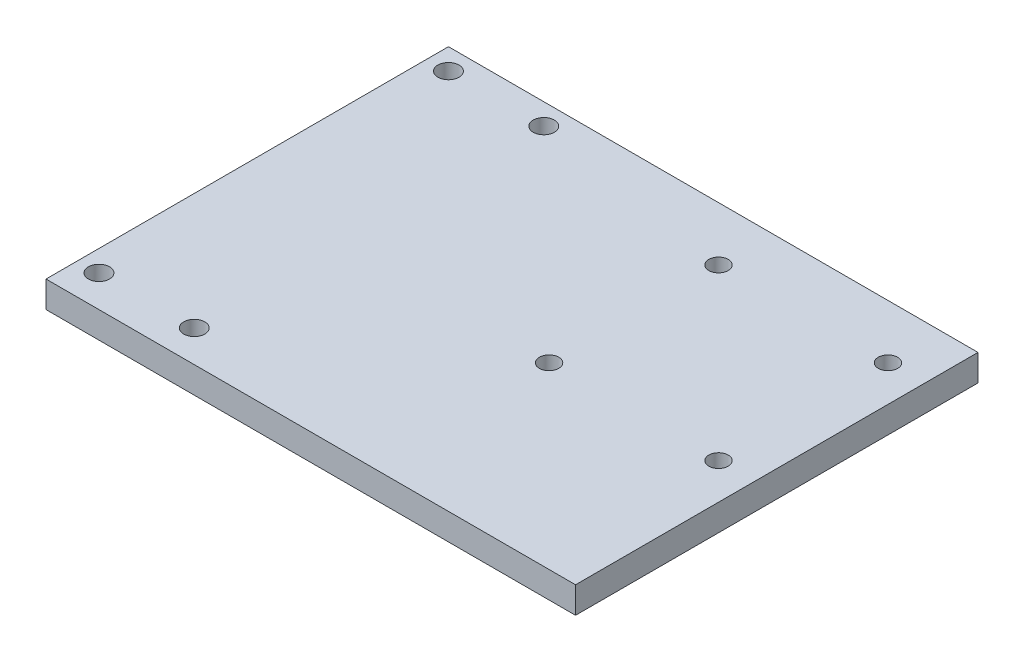
from build123d import *

# Parameters (mm, degrees)
SKETCH1_W           = 100
SKETCH1_H           = 76
BOSS_EXTRUDE1_DEPTH = 5
CUT_EXTRUDE6_REACH  = 7
SKETCH2_R           = 2
SKETCH2_R_2         = 1.832419899


with BuildPart() as part:
    # Sketch1 → Boss-Extrude1 (new body)
    with BuildSketch(Plane(origin=(0, 0, 0), x_dir=(1, 0, 0), z_dir=(0, 1, 0))):
        Rectangle(SKETCH1_W, SKETCH1_H)
    extrude(amount=BOSS_EXTRUDE1_DEPTH)

    # Sketch2 → Cut-Extrude6 (cut, up to next)
    with BuildSketch(Plane(origin=(0, 5, 0), x_dir=(1, 0, 0), z_dir=(0, 1, 0)), mode=Mode.PRIVATE) as cut_extrude6_sk1:
        with Locations((-46, 34)):
            Circle(SKETCH2_R)
    cut_extrude6_tool1 = extrude(cut_extrude6_sk1.sketch, amount=-CUT_EXTRUDE6_REACH, mode=Mode.PRIVATE) & part.part
    add(cut_extrude6_tool1.solids().sort_by_distance((-46, 5, -34))[0], mode=Mode.SUBTRACT)
    # Sketch2 → Cut-Extrude6 (cut, up to next)
    with BuildSketch(Plane(origin=(0, 5, 0), x_dir=(1, 0, 0), z_dir=(0, 1, 0)), mode=Mode.PRIVATE) as cut_extrude6_sk2:
        with Locations((-28, 34)):
            Circle(SKETCH2_R)
    cut_extrude6_tool2 = extrude(cut_extrude6_sk2.sketch, amount=-CUT_EXTRUDE6_REACH, mode=Mode.PRIVATE) & part.part
    add(cut_extrude6_tool2.solids().sort_by_distance((-28, 5, -34))[0], mode=Mode.SUBTRACT)
    # Sketch2 → Cut-Extrude6 (cut, up to next)
    with BuildSketch(Plane(origin=(0, 5, 0), x_dir=(1, 0, 0), z_dir=(0, 1, 0)), mode=Mode.PRIVATE) as cut_extrude6_sk3:
        with Locations((-46, -32)):
            Circle(SKETCH2_R)
    cut_extrude6_tool3 = extrude(cut_extrude6_sk3.sketch, amount=-CUT_EXTRUDE6_REACH, mode=Mode.PRIVATE) & part.part
    add(cut_extrude6_tool3.solids().sort_by_distance((-46, 5, 32))[0], mode=Mode.SUBTRACT)
    # Sketch2 → Cut-Extrude6 (cut, up to next)
    with BuildSketch(Plane(origin=(0, 5, 0), x_dir=(1, 0, 0), z_dir=(0, 1, 0)), mode=Mode.PRIVATE) as cut_extrude6_sk4:
        with Locations((-28, -32)):
            Circle(SKETCH2_R)
    cut_extrude6_tool4 = extrude(cut_extrude6_sk4.sketch, amount=-CUT_EXTRUDE6_REACH, mode=Mode.PRIVATE) & part.part
    add(cut_extrude6_tool4.solids().sort_by_distance((-28, 5, 32))[0], mode=Mode.SUBTRACT)
    # Sketch2 → Cut-Extrude6 (cut, up to next)
    with BuildSketch(Plane(origin=(0, 5, 0), x_dir=(1, 0, 0), z_dir=(0, 1, 0)), mode=Mode.PRIVATE) as cut_extrude6_sk5:
        with Locations((11.2, 27.8)):
            Circle(SKETCH2_R_2)
    cut_extrude6_tool5 = extrude(cut_extrude6_sk5.sketch, amount=-CUT_EXTRUDE6_REACH, mode=Mode.PRIVATE) & part.part
    add(cut_extrude6_tool5.solids().sort_by_distance((11.2, 5, -27.8))[0], mode=Mode.SUBTRACT)
    # Sketch2 → Cut-Extrude6 (cut, up to next)
    with BuildSketch(Plane(origin=(0, 5, 0), x_dir=(1, 0, 0), z_dir=(0, 1, 0)), mode=Mode.PRIVATE) as cut_extrude6_sk6:
        with Locations((43.2, 27.8)):
            Circle(SKETCH2_R_2)
    cut_extrude6_tool6 = extrude(cut_extrude6_sk6.sketch, amount=-CUT_EXTRUDE6_REACH, mode=Mode.PRIVATE) & part.part
    add(cut_extrude6_tool6.solids().sort_by_distance((43.2, 5, -27.8))[0], mode=Mode.SUBTRACT)
    # Sketch2 → Cut-Extrude6 (cut, up to next)
    with BuildSketch(Plane(origin=(0, 5, 0), x_dir=(1, 0, 0), z_dir=(0, 1, 0)), mode=Mode.PRIVATE) as cut_extrude6_sk7:
        with Locations((11.2, -4.2)):
            Circle(SKETCH2_R_2)
    cut_extrude6_tool7 = extrude(cut_extrude6_sk7.sketch, amount=-CUT_EXTRUDE6_REACH, mode=Mode.PRIVATE) & part.part
    add(cut_extrude6_tool7.solids().sort_by_distance((11.2, 5, 4.2))[0], mode=Mode.SUBTRACT)
    # Sketch2 → Cut-Extrude6 (cut, up to next)
    with BuildSketch(Plane(origin=(0, 5, 0), x_dir=(1, 0, 0), z_dir=(0, 1, 0)), mode=Mode.PRIVATE) as cut_extrude6_sk8:
        with Locations((43.2, -4.2)):
            Circle(SKETCH2_R_2)
    cut_extrude6_tool8 = extrude(cut_extrude6_sk8.sketch, amount=-CUT_EXTRUDE6_REACH, mode=Mode.PRIVATE) & part.part
    add(cut_extrude6_tool8.solids().sort_by_distance((43.2, 5, 4.2))[0], mode=Mode.SUBTRACT)


solid = part.part
